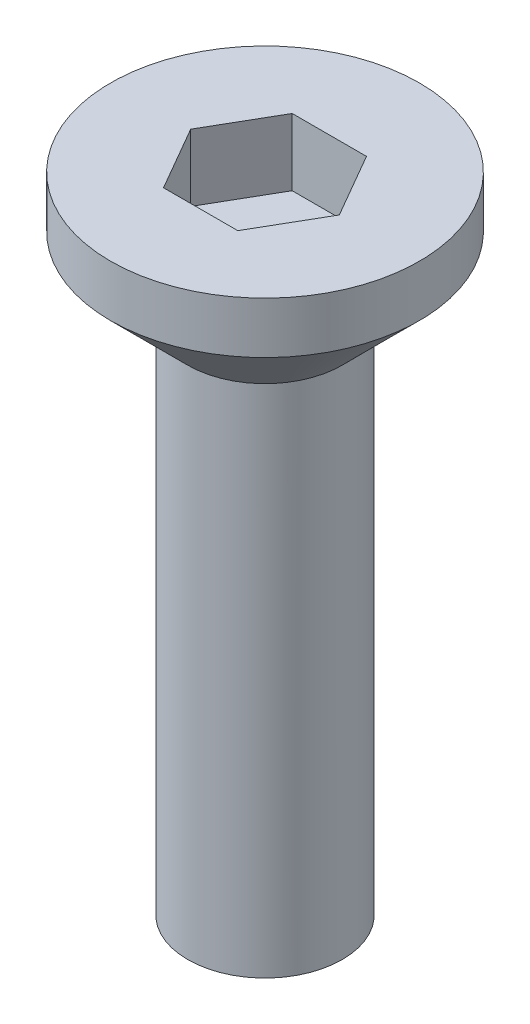
from build123d import *

# Parameters (mm, degrees)
SKETCH_1_R            = 3
EXTRUDE_251_DEPTH     = 2.5
CHAMFER_1_SIZE        = 1.5
CUT_EXTRUDE_459_DEPTH = 1.3
SKETCH_3_R            = 1.5
EXTRUDE_571_DEPTH     = 10


with BuildPart() as part:
    # 草图1 → Extrude 251 (new body)
    with BuildSketch(Plane(origin=(0, 0, 0), x_dir=(1, 0, 0), z_dir=(0, 1, 0))):
        Circle(SKETCH_1_R)
    extrude(amount=EXTRUDE_251_DEPTH)

    # 倒角1
    chamfer_1_edges = [part.edges().sort_by_distance(p)[0] for p in [
        (-3, 0, 0),
    ]]
    chamfer(chamfer_1_edges, length=CHAMFER_1_SIZE)

    # 草图2 → Cut-Extrude 459 (cut)
    with BuildSketch(Plane(origin=(0, 2.5, 0), x_dir=(1, 0, 0), z_dir=(0, 1, 0))):
        Polygon((1.443375673, 0), (0.721687836, 1.25), (-0.721687836, 1.25), (-1.443375673, 0), (-0.721687836, -1.25), (0.721687836, -1.25), align=None)
    extrude(amount=-CUT_EXTRUDE_459_DEPTH, mode=Mode.SUBTRACT)

    # 草图3 → Extrude 571 (add)
    with BuildSketch(Plane.XZ):
        Circle(SKETCH_3_R)
    extrude(amount=EXTRUDE_571_DEPTH)


solid = part.part
